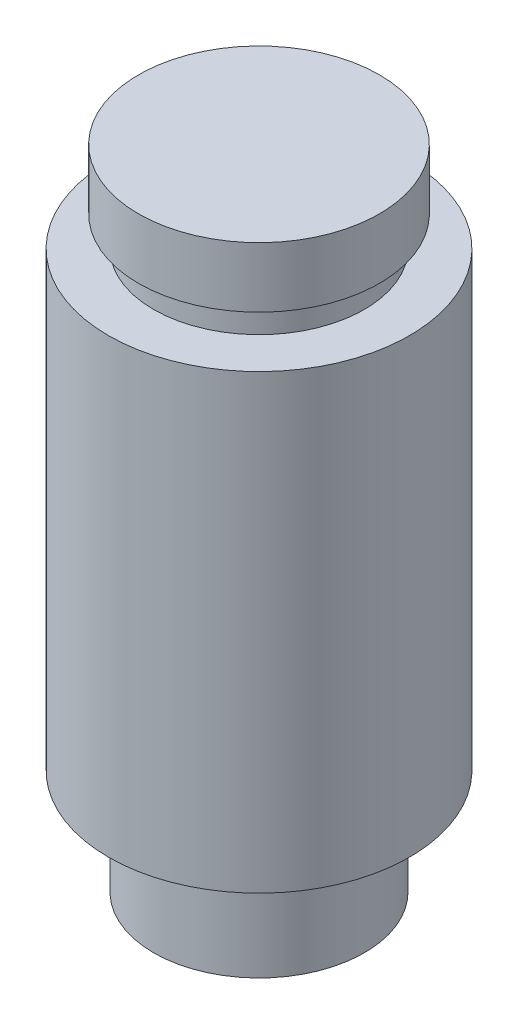
from build123d import *


with BuildPart() as part:
    # Sketch1 → Revolve1 (revolve)
    with BuildSketch(Plane.XY):
        Polygon((0, 0), (0, 54.61), (10.16, 54.61), (10.16, 49.53), (8.89, 49.53), (8.89, 46.99), (12.7, 46.99), (12.7, 8.89), (8.89, 8.89), (8.89, 0), align=None)
    revolve(axis=Axis((0, 0, 0), (0, 1, 0)))


solid = part.part
